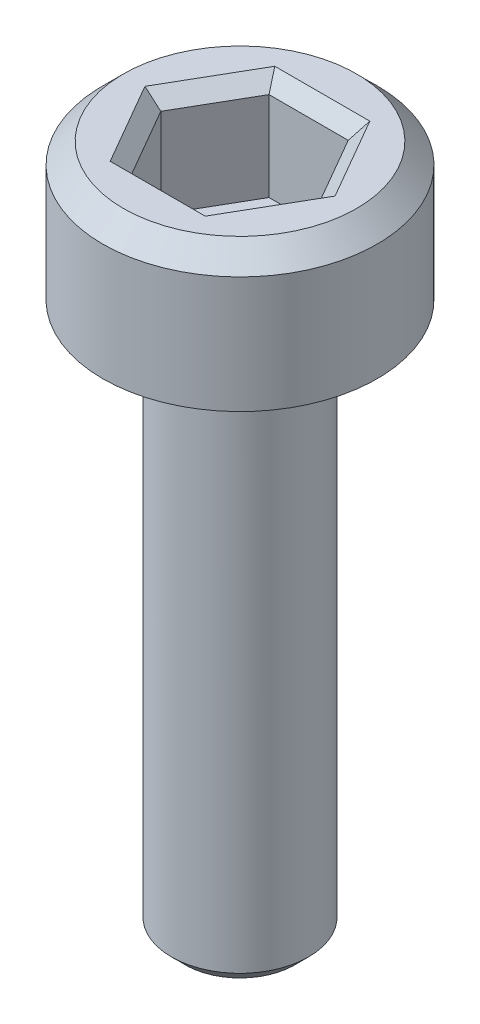
from build123d import *

# Parameters (mm, degrees)
SKETCH1_R           = 2
BOSS_EXTRUDE1_DEPTH = 2
CHAMFER1_SIZE       = 0.3
CUT_EXTRUDE1_DEPTH  = 1.5
CHAMFER2_SIZE       = 0.2
SKETCH3_R           = 1
BOSS_EXTRUDE2_DEPTH = 8
CHAMFER3_SIZE       = 0.2


with BuildPart() as part:
    # Sketch1 → Boss-Extrude1 (new body)
    with BuildSketch(Plane(origin=(0, 0, 0), x_dir=(1, 0, 0), z_dir=(0, 1, 0))):
        with Locations(Location((0, 0, 0), (0, 0, 270))):  # turned: the seam where the file's is
            Circle(SKETCH1_R)
    extrude(amount=BOSS_EXTRUDE1_DEPTH)

    # Chamfer1
    chamfer1_edges = [part.edges().sort_by_distance(p)[0] for p in [
        (0, 2, -2),
    ]]
    chamfer(chamfer1_edges, length=CHAMFER1_SIZE)

    # Sketch2 → Cut-Extrude1 (cut)
    with BuildSketch(Plane(origin=(0, 2, 0), x_dir=(1, 0, 0), z_dir=(0, 1, 0))):
        Polygon((1.154700538, 0), (0.577350269, 1), (-0.577350269, 1), (-1.154700538, 0), (-0.577350269, -1), (0.577350269, -1), align=None)
    extrude(amount=-CUT_EXTRUDE1_DEPTH, mode=Mode.SUBTRACT)

    # Chamfer2
    chamfer2_edges = [part.edges().sort_by_distance(p)[0] for p in [
        (0.866025404, 2, 0.5),
        (0.866025404, 2, -0.5),
        (0, 2, -1),
        (-0.866025404, 2, -0.5),
        (-0.866025404, 2, 0.5),
        (0, 2, 1),
    ]]
    chamfer(chamfer2_edges, length=CHAMFER2_SIZE)

    # Sketch3 → Boss-Extrude2 (add)
    with BuildSketch(Plane.XZ):
        with Locations(Location((0, 0, 0), (0, 0, 90))):  # turned: the seam where the file's is
            Circle(SKETCH3_R)
    extrude(amount=BOSS_EXTRUDE2_DEPTH)

    # Chamfer3
    chamfer3_edges = [part.edges().sort_by_distance(p)[0] for p in [
        (0, -8, -1),
    ]]
    chamfer(chamfer3_edges, length=CHAMFER3_SIZE)


solid = part.part
